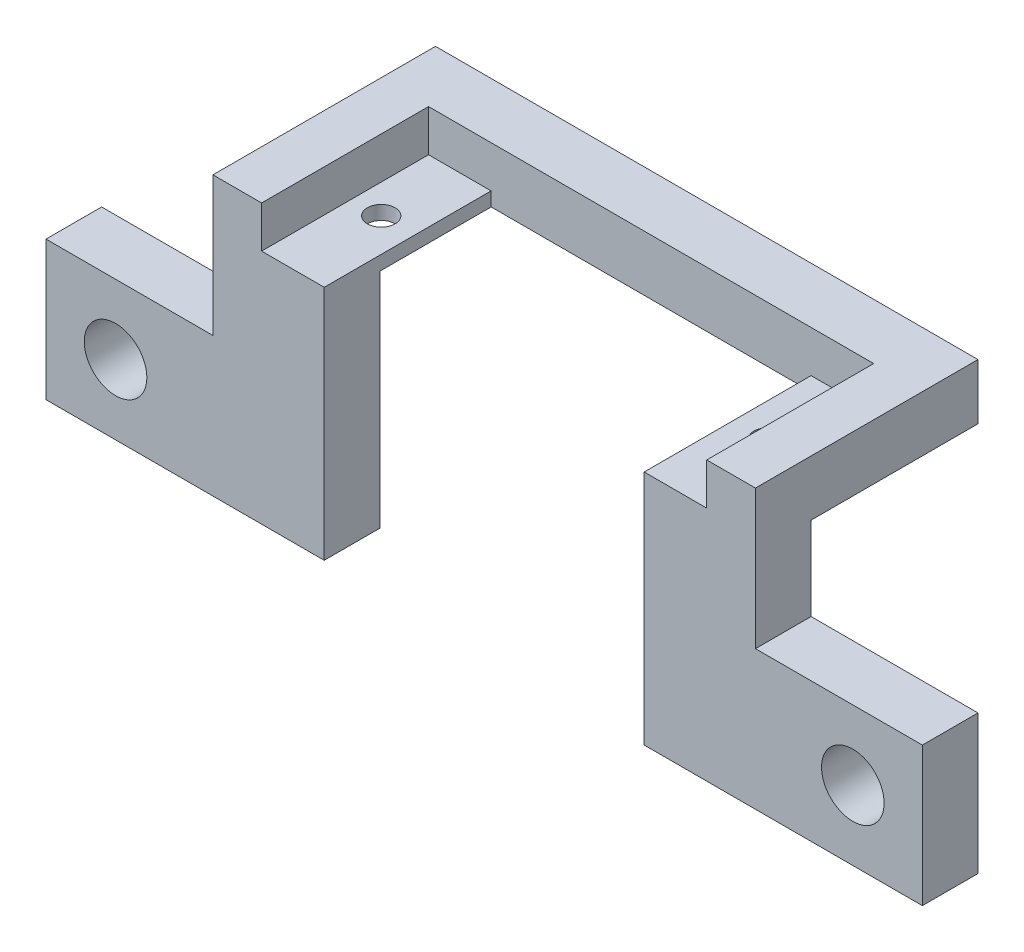
from build123d import *

# Parameters (mm, degrees)
RESSALTO_EXTRUS_O1_DEPTH   = 4
FURO_DE_DI_METRO_2_0_2_1_D = 2
RESSALTO_EXTRUS_O2_DEPTH   = 4
FURO_COM_FOLGA_DE_M41_D    = 4.5
ESBO_O6_W                  = 32
ESBO_O6_H                  = 12
CORTE_EXTRUS_O1_DEPTH      = 3


with BuildPart() as part:
    # Esboço1 → Ressalto-extrusão1 (new body)
    with BuildSketch(Plane(origin=(0, 0, 0), x_dir=(1, 0, 0), z_dir=(0, 1, 0))):
        Polygon((-19.5, 4), (-19.5, -12), (-11.5, -12), (-11.5, 0), (11.5, 0), (11.5, -12), (19.5, -12), (19.5, 4), align=None)
    extrude(amount=RESSALTO_EXTRUS_O1_DEPTH)

    # Furo de diâmetro Ø2.0 (2)1 (through all)
    with Locations(Plane(origin=(-13.9, 4, 5.5), x_dir=(0, 0, 1), z_dir=(0, 1, 0))):
        with Locations((0, 0), (0, 27.8)):
            Hole(FURO_DE_DI_METRO_2_0_2_1_D / 2)

    # Esboço4 → Ressalto-extrusão2 (add)
    with BuildSketch(Plane.XY.offset(12)):
        Polygon((31.5, -16), (31.5, -6), (19.5, -6), (19.5, 4), (11.5, 4), (11.5, -16), align=None)
        Polygon((-19.5, 4), (-11.5, 4), (-11.5, -16), (-31.5, -16), (-31.5, -6), (-19.5, -6), align=None)
    extrude(amount=-RESSALTO_EXTRUS_O2_DEPTH)

    # Furo com folga de M41 (through all)
    with Locations(Plane(origin=(-26.5, -11, 12), x_dir=(1, 0, 0), z_dir=(0, 0, 1))):
        with Locations((0, 0), (53, 0)):
            Hole(FURO_COM_FOLGA_DE_M41_D / 2)

    # Esboço6 → Corte-extrusão1 (cut)
    with BuildSketch(Plane(origin=(0, 4, 0), x_dir=(1, 0, 0), z_dir=(0, 1, 0))):
        with Locations((0, -6)):
            Rectangle(ESBO_O6_W, ESBO_O6_H)
    extrude(amount=-CORTE_EXTRUS_O1_DEPTH, mode=Mode.SUBTRACT)


solid = part.part
